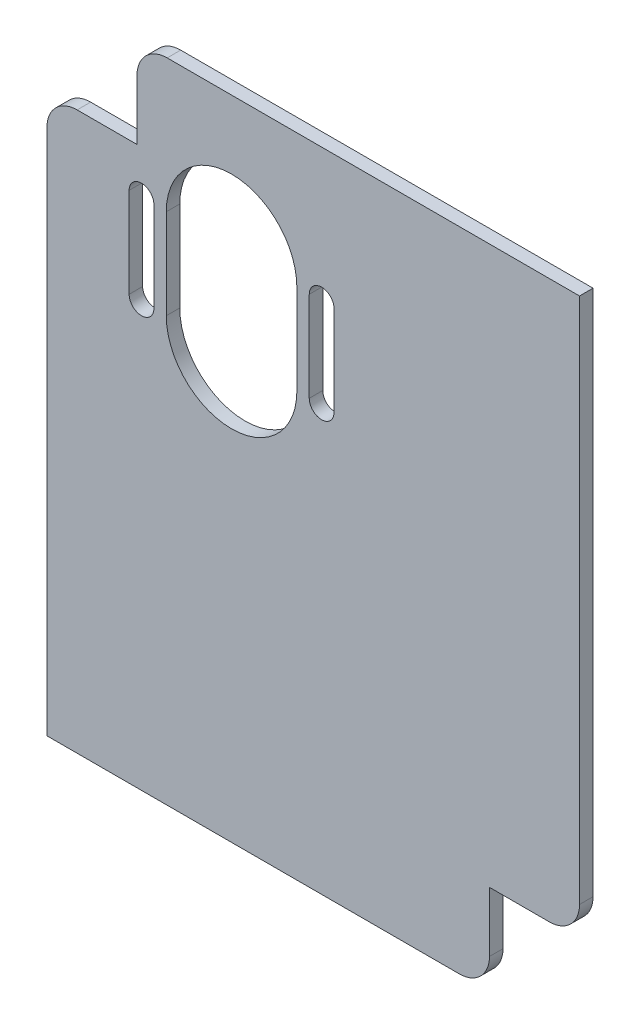
from build123d import *

# Parameters (mm, degrees)
SKETCH1_W           = 118.275
SKETCH1_H           = 143.74
BOSS_EXTRUDE1_DEPTH = 3
CUT_EXTRUDE1_DEPTH  = 3
SKETCH3_W           = 20
SKETCH3_H           = 20
CUT_EXTRUDE2_DEPTH  = 10
FILLET1_R           = 6.7


with BuildPart() as part:
    # Sketch1 → Boss-Extrude1 (new body)
    with BuildSketch(Plane.XY):
        with Locations((59.1375, 71.87)):
            Rectangle(SKETCH1_W, SKETCH1_H)
    extrude(amount=BOSS_EXTRUDE1_DEPTH)

    # Sketch2 → Cut-Extrude1 (cut)
    with BuildSketch(Plane.XY.offset(3)):
        with BuildLine():
            Line((55.5, 114.05), (55.5, 94.05))
            ThreePointArc((55.5, 94.05), (41, 79.55), (26.5, 94.05))
            Line((26.5, 94.05), (26.5, 114.05))
            ThreePointArc((26.5, 114.05), (41, 128.55), (55.5, 114.05))
        make_face()
        with BuildLine():
            Line((63.75, 114.05), (63.75, 94.05))
            ThreePointArc((63.75, 94.05), (61, 91.3), (58.25, 94.05))
            Line((58.25, 94.05), (58.25, 114.05))
            ThreePointArc((58.25, 114.05), (61, 116.8), (63.75, 114.05))
        make_face()
        with BuildLine():
            Line((23.75, 114.05), (23.75, 94.05))
            ThreePointArc((23.75, 94.05), (21, 91.3), (18.25, 94.05))
            Line((18.25, 94.05), (18.25, 114.05))
            ThreePointArc((18.25, 114.05), (21, 116.8), (23.75, 114.05))
        make_face()
    extrude(amount=-CUT_EXTRUDE1_DEPTH, mode=Mode.SUBTRACT)

    # Sketch3 → Cut-Extrude2 (cut)
    with BuildSketch(Plane.XY.offset(3)):
        with Locations((10, 133.74)):
            Rectangle(SKETCH3_W, SKETCH3_H)
        with Locations((108.275, 10)):
            Rectangle(SKETCH3_W, SKETCH3_H)
    extrude(amount=-CUT_EXTRUDE2_DEPTH, mode=Mode.SUBTRACT)

    # Fillet1
    fillet1_edges = [part.edges().sort_by_distance(p)[0] for p in [
        (0, 123.74, 1.5),
        (20, 143.74, 1.5),
        (118.275, 20, 1.5),
        (98.275, 0, 1.5),
    ]]
    fillet(fillet1_edges, radius=FILLET1_R)


solid = part.part
